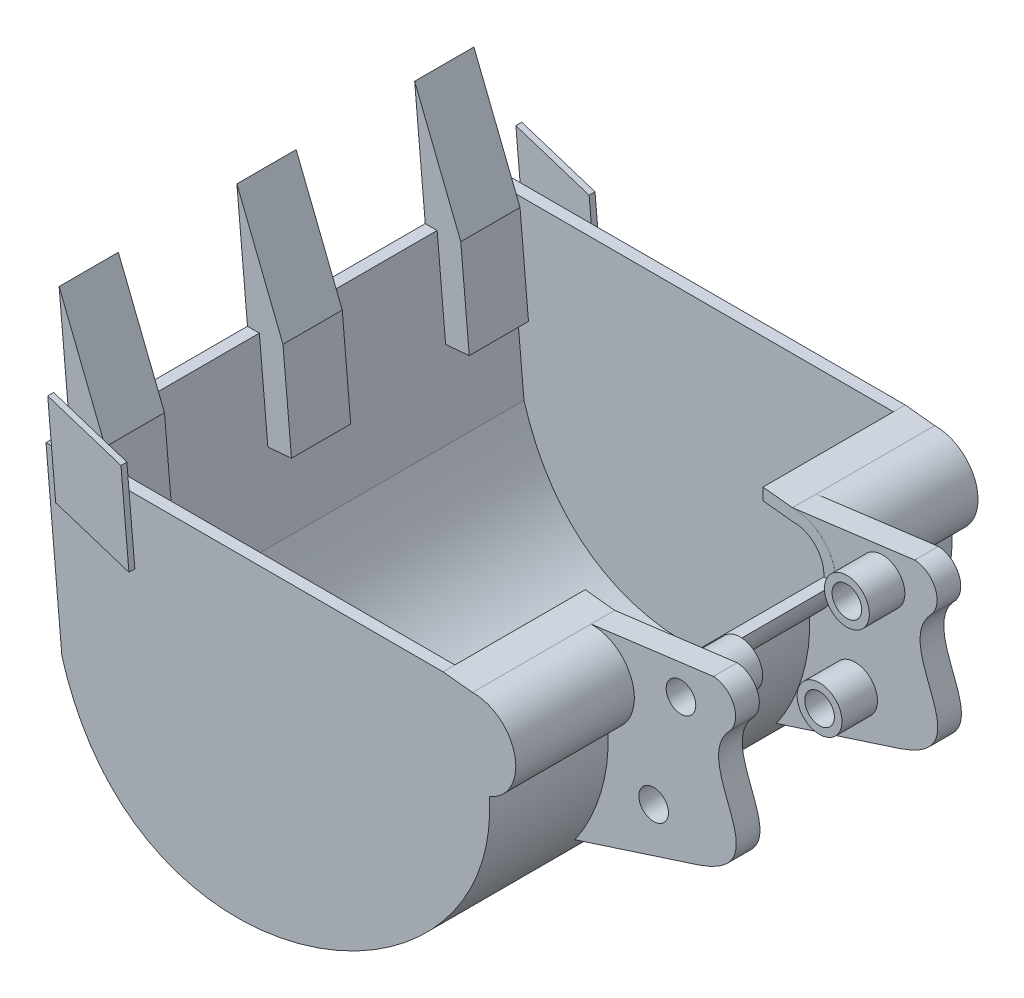
from build123d import *

# Parameters (mm, degrees)
BASIC_GEOMETRY_DEPTH   = 195
REMOVE_MATERIAL_T      = -10
TEETH_START            = 10
TEETH_DEPTH            = 50
SKETCH2_W              = 94.171868374
SKETCH2_H              = 370
REMOVE_MATERIAL2_DEPTH = 50
TEETH_PATTERN_COUNT    = 3
TEETH_PATTERN_PITCH    = 150
SIDE_PLATE_DEPTH       = 5
BOSS_EXTRUDE6_START    = 75
BOSS_EXTRUDE6_DEPTH    = 20
LPATTERN4_COUNT        = 2
LPATTERN4_PITCH        = 170
SKETCH10_R             = 12.5
CUT_EXTRUDE4_DEPTH     = 485.783096914
SKETCH11_R             = 18.911522993
SKETCH11_R_2           = 12.5
BOSS_EXTRUDE7_DEPTH    = 30
LPATTERN7_COUNT        = 2
LPATTERN7_PITCH        = 120
SKETCH13_W             = 150
SKETCH13_H             = 40
CUT_EXTRUDE5_DEPTH     = 70


with BuildPart() as part:
    # Sketch1 → Basic_geometry (new, symmetric)
    with BuildSketch(Plane.XY):
        with BuildLine():
            Line((130, 0), (-130, 0))
            Line((-130, 0), (-205, 0))
            Line((-205, 0), (-191.591883356, -149.399539518))
            add(Edge.make_bspline(
                [(-191.591883356, -149.399539518), (-126.425268405, -370.090746117), (179.854093021, -241.359443475), (169.099924805, -71.562234879)],
                knots=[0, 0, 0, 0, 1, 1, 1, 1], degree=3))
            ThreePointArc((169.099924805, -71.562234879), (190.665817888, -31.179766144), (154.858649571, -2.654720612))
            Line((154.858649571, -2.654720612), (130, 0))
        make_face()
    extrude(amount=BASIC_GEOMETRY_DEPTH, both=True)

    # Remove_material
    remove_material_openings = [part.faces().sort_by_distance(p)[0] for p in [
        (-37.5, 0, 0),
    ]]
    offset(amount=REMOVE_MATERIAL_T, openings=remove_material_openings, kind=Kind.INTERSECTION)

    # Sketch7 → Teeth (add)
    with BuildSketch(Plane.XY.offset(-185).offset(TEETH_START)):
        Polygon((-205, 0), (-213.938744429, 99.599693012), (-175.039869809, 1.787748886), (-167.888874266, -77.892005523), (-187.808812868, -79.679754409), (-194.959808411, 0), align=None)
    teeth = extrude(amount=TEETH_DEPTH)

    # Sketch2 → Remove_material2 (cut)
    with BuildSketch(Plane(origin=(0, 0, 0), x_dir=(1, 0, 0), z_dir=(0, 1, 0))):
        with Locations((82.914065813, 0)):
            Rectangle(SKETCH2_W, SKETCH2_H)
    extrude(amount=-REMOVE_MATERIAL2_DEPTH, mode=Mode.SUBTRACT)

    # Teeth_pattern: Teeth ×3
    with Locations(*[(0, 0, i * TEETH_PATTERN_PITCH) for i in range(1, TEETH_PATTERN_COUNT)]):
        add(teeth)

    # Sketch8 → Side_plate (add)
    with BuildSketch(Plane.XY.offset(195)):
        Polygon((-194.959808411, 0), (-198.535306183, 39.839877205), (-136.747557297, 19.919938602), (-134.959808411, 0), (-130.043498975, -54.779831156), (-191.831247861, -34.859892554), align=None)
    side_plate = extrude(amount=SIDE_PLATE_DEPTH)

    # Side_plate_mirror: Side_plate across plane
    add(side_plate.mirror(Plane.XY))

    # Sketch13 → Cut-Extrude5 (cut)
    with BuildSketch(Plane.ZY.offset(-130)):
        with Locations((0, -20)):
            Rectangle(SKETCH13_W, SKETCH13_H)
    extrude(amount=-CUT_EXTRUDE5_DEPTH, mode=Mode.SUBTRACT)


with BuildPart() as body_2:
    # Sketch9 → Boss-Extrude6 (new body)
    with BuildSketch(Plane.XY.offset(BOSS_EXTRUDE6_START)):
        with BuildLine():
            Line((141.296742224, -167.057120142), (245.967438276, -133.233380134))
            add(Edge.make_bspline(
                [(272.594670811, -21.462325491), (235.113232038, -59.333448742), (319.872555968, -107.999027182), (245.967438276, -133.233380134)],
                knots=[0, 0, 0, 0, 1, 1, 1, 1], degree=3))
            ThreePointArc((272.594670811, -21.462325491), (275.102934155, -0.986118764), (258.099927413, 10.695669998))
            Line((258.099927413, 10.695669998), (154.858649571, -2.654720612))
            ThreePointArc((154.858649571, -2.654720612), (190.665817888, -31.179766144), (169.099924805, -71.562234879))
            ThreePointArc((169.099924805, -71.562234879), (163.062439638, -121.599299387), (141.296742224, -167.057120142))
        make_face()
    boss_extrude6 = extrude(amount=BOSS_EXTRUDE6_DEPTH)


with BuildPart() as lpattern4_1:
    # LPattern4: Boss-Extrude6 ×2
    with Locations(*[(0, 0, -i * LPATTERN4_PITCH) for i in range(1, LPATTERN4_COUNT)]):
        add(boss_extrude6)


with BuildPart() as cut_extrude4_tool:
    # Sketch10 → Cut-Extrude4 (new, through all)
    with BuildSketch(Plane.XY.offset(95)):
        with Locations(Location((230.762415937, -18.047567767, 0), (0, 0, 180))):
            Circle(SKETCH10_R)
        with Locations(Location((207.704013235, -108.047567767, 0), (0, 0, 180))):
            Circle(SKETCH10_R)
    extrude(amount=-CUT_EXTRUDE4_DEPTH)


with BuildPart() as body_2_1:
    add(body_2.part)

    # Cut-Extrude4: cut by cut_extrude4_tool
    add(cut_extrude4_tool.part, mode=Mode.SUBTRACT)

    # Sketch11 → Boss-Extrude7 (add)
    with BuildSketch(Plane(origin=(0, 0, 75), x_dir=(-1, 0, 0), z_dir=(0, 0, -1))):
        with Locations((-230.762415937, -18.047567767)):
            Circle(SKETCH11_R)
        with Locations((-230.762415937, -18.047567767)):
            Circle(SKETCH11_R_2, mode=Mode.SUBTRACT)
        with Locations((-207.704013235, -108.047567767)):
            Circle(SKETCH11_R)
        with Locations((-207.704013235, -108.047567767)):
            Circle(SKETCH11_R_2, mode=Mode.SUBTRACT)
    boss_extrude7 = extrude(amount=BOSS_EXTRUDE7_DEPTH)


with BuildPart() as lpattern4_1_1:
    add(lpattern4_1.part)

    # Cut-Extrude4: cut by cut_extrude4_tool
    add(cut_extrude4_tool.part, mode=Mode.SUBTRACT)

    # LPattern7: Boss-Extrude7 ×2
    with Locations(*[(0, 0, -i * LPATTERN7_PITCH) for i in range(1, LPATTERN7_COUNT)]):
        add(boss_extrude7)


solid = Compound([part.part, body_2_1.part, lpattern4_1_1.part])
